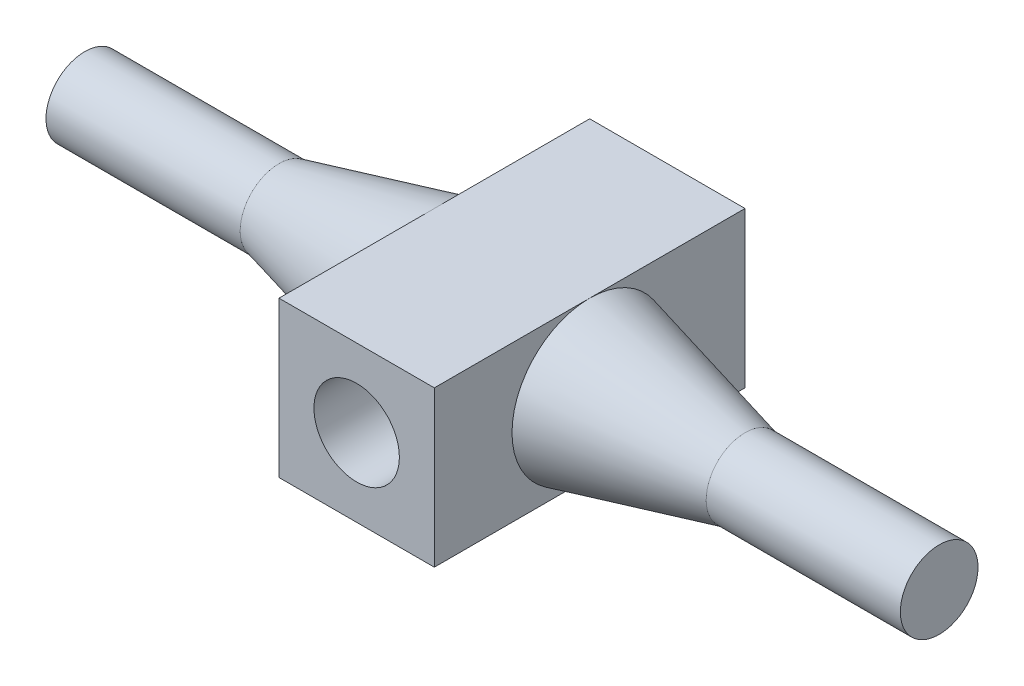
from build123d import *

# Parameters (mm, degrees)
SKETCH1_W           = 2
SKETCH1_H           = 2
SKETCH1_R           = 0.55
BOSS_EXTRUDE1_DEPTH = 4


with BuildPart() as part:
    # Sketch1 → Boss-Extrude1 (new body)
    with BuildSketch(Plane.XY):
        Rectangle(SKETCH1_W, SKETCH1_H)
        Circle(SKETCH1_R, mode=Mode.SUBTRACT)
    extrude(amount=BOSS_EXTRUDE1_DEPTH)

    # 草图1 → 旋转1 (revolve)
    with BuildSketch(Plane.XY.offset(2)):
        Polygon((1, 1), (1, 0), (5.5, 0), (5.5, 0.5), (3, 0.5), align=None)
        Polygon((-1, 0), (-5.5, 0), (-5.5, 0.5), (-3, 0.5), (-1, 1), align=None)
    revolve(axis=Axis((-1, 0, 2), (-1, 0, 0)))


solid = part.part
